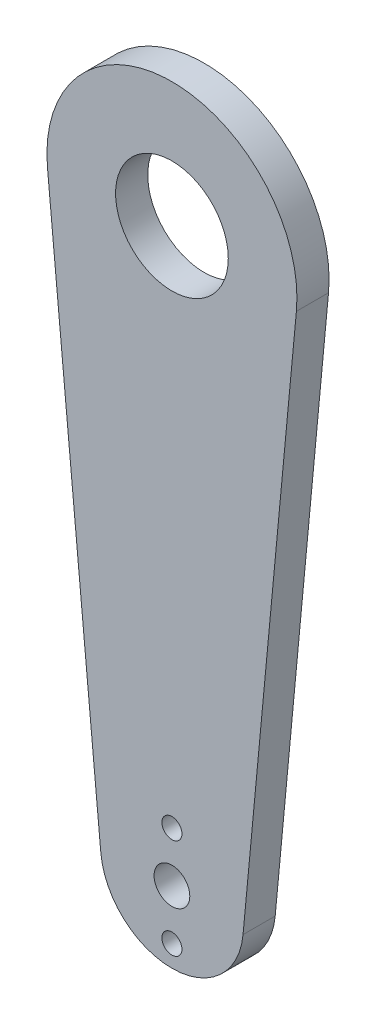
from build123d import *

# Parameters (mm, degrees)
SKETCH1_R           = 7.8875
SKETCH1_R_2         = 2.5
SKETCH1_R_3         = 1.4
BOSS_EXTRUDE1_DEPTH = 4.5


with BuildPart() as part:
    # Sketch1 → Boss-Extrude1 (new body)
    with BuildSketch(Plane.XY):
        with BuildLine():
            Line((-9.955957701, -0.9375), (-17.422925977, 78.359375))
            ThreePointArc((-17.422925977, 78.359375), (0, 97.5), (17.422925977, 78.359375))
            Line((17.422925977, 78.359375), (9.955957701, -0.9375))
            ThreePointArc((9.955957701, -0.9375), (0, -10), (-9.955957701, -0.9375))
        make_face()
        with Locations((0, 80)):
            Circle(SKETCH1_R, mode=Mode.SUBTRACT)
        Circle(SKETCH1_R_2, mode=Mode.SUBTRACT)
        with Locations((0, 7)):
            Circle(SKETCH1_R_3, mode=Mode.SUBTRACT)
        with Locations((0, -7)):
            Circle(SKETCH1_R_3, mode=Mode.SUBTRACT)
    extrude(amount=BOSS_EXTRUDE1_DEPTH)


solid = part.part
